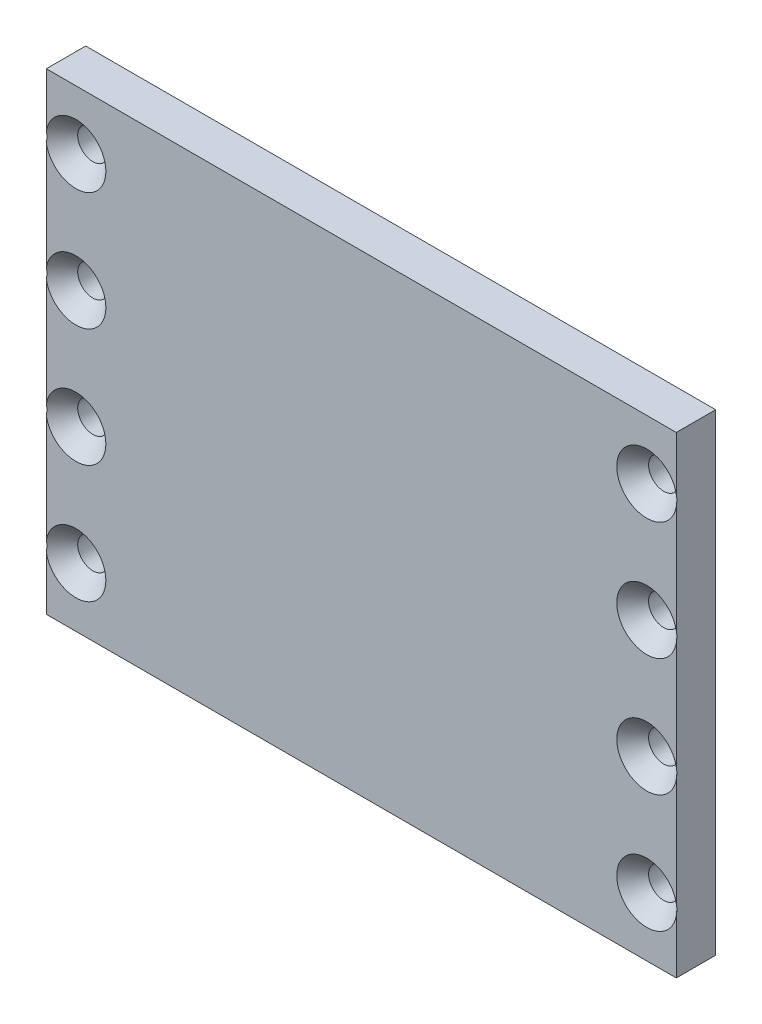
from build123d import *

# Parameters (mm, degrees)
SKETCH1_W                                        = 203.2
SKETCH1_H                                        = 152.4
BOSS_EXTRUDE1_DEPTH                              = 12.7
CSK_FOR_3_8_FLAT_HEAD_MACHINE_SCREW1_D           = 9.8044
CSK_FOR_3_8_FLAT_HEAD_MACHINE_SCREW1_CSINK_D     = 19.3548
CSK_FOR_3_8_FLAT_HEAD_MACHINE_SCREW1_CSINK_ANGLE = 82


with BuildPart() as part:
    # Sketch1 → Boss-Extrude1 (new body)
    with BuildSketch(Plane.XY):
        Rectangle(SKETCH1_W, SKETCH1_H)
    extrude(amount=BOSS_EXTRUDE1_DEPTH)

    # CSK for 3/8 Flat Head Machine Screw1 (through all)
    with Locations(Plane.XY.offset(12.7)):
        with Locations((-92.075, 57.15), (-92.075, -57.15), (92.075, -57.15), (92.075, 57.15), (-92.075, 19.05), (92.075, 19.05), (92.075, -19.05), (-92.075, -19.05)):
            CounterSinkHole(CSK_FOR_3_8_FLAT_HEAD_MACHINE_SCREW1_D / 2, CSK_FOR_3_8_FLAT_HEAD_MACHINE_SCREW1_CSINK_D / 2, counter_sink_angle=CSK_FOR_3_8_FLAT_HEAD_MACHINE_SCREW1_CSINK_ANGLE)


solid = part.part
